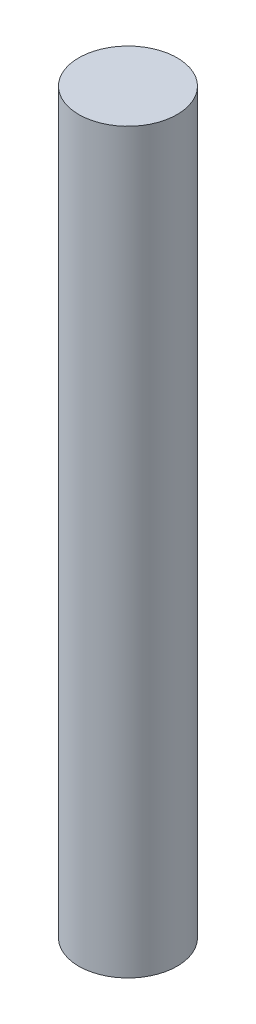
from build123d import *

# Parameters (mm, degrees)
SKETCH1_R           = 9
BOSS_EXTRUDE1_DEPTH = 135


with BuildPart() as part:
    # Sketch1 → Boss-Extrude1 (new body)
    with BuildSketch(Plane(origin=(0, 0, 0), x_dir=(1, 0, 0), z_dir=(0, 1, 0))):
        Circle(SKETCH1_R)
    extrude(amount=BOSS_EXTRUDE1_DEPTH)


solid = part.part
